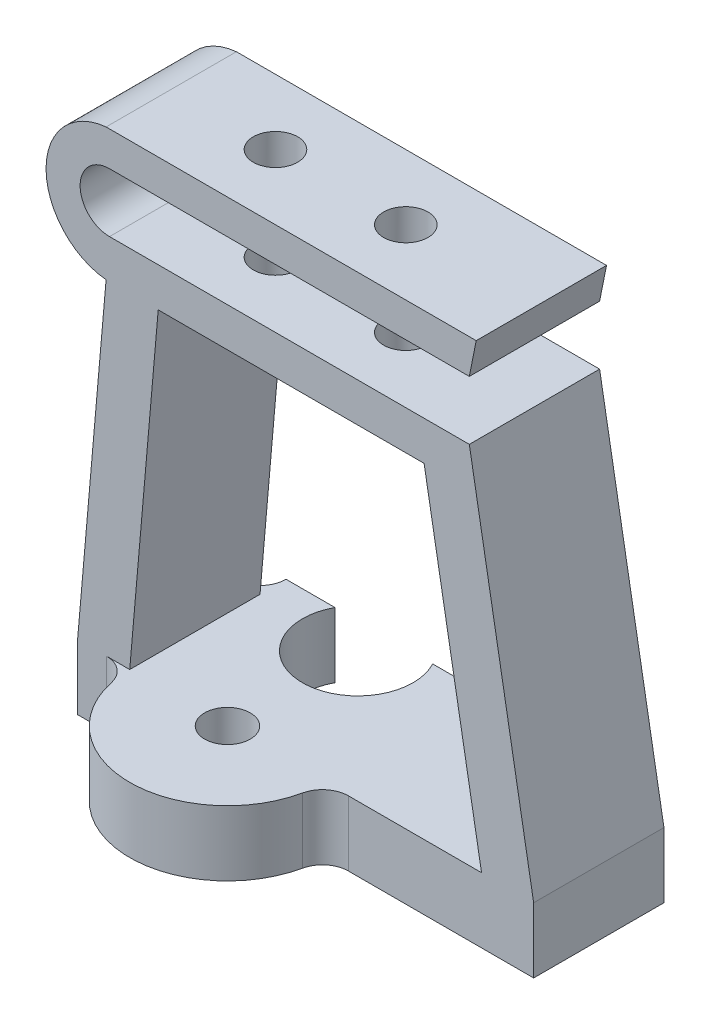
from build123d import *

# Parameters (mm, degrees)
SKETCH1_R           = 4.25
SKETCH1_R_2         = 1.75
BOSS_EXTRUDE1_DEPTH = 5
SKETCH2_W           = 10
SKETCH2_H           = 5
BOSS_EXTRUDE2_DEPTH = 16
BOSS_EXTRUDE4_START = -15
SKETCH2_2_W         = 10
SKETCH2_2_H         = 5
BOSS_EXTRUDE4_DEPTH = 4
BOSS_EXTRUDE5_DEPTH = 10
BOSS_EXTRUDE6_DEPTH = 10
FILLET7_R           = 2
SKETCH8_W           = 24.049628059
SKETCH8_H           = 16.756852772
CUT_EXTRUDE1_DEPTH  = 6
SKETCH9_R           = 1.7
CUT_EXTRUDE2_DEPTH  = 10.15756


with BuildPart() as part:
    # Sketch1 → Boss-Extrude1 (new body)
    with BuildSketch(Plane(origin=(0, 0, 0), x_dir=(1, 0, 0), z_dir=(0, 1, 0))):
        with BuildLine():
            Line((-7.5, -10), (-7.5, 10))
            ThreePointArc((-7.5, 10), (0, 17.5), (7.5, 10))
            Line((7.5, 10), (7.5, -10))
            ThreePointArc((7.5, -10), (0, -17.5), (-7.5, -10))
        make_face()
        Circle(SKETCH1_R, mode=Mode.SUBTRACT)
        with Locations((0, 10)):
            Circle(SKETCH1_R_2, mode=Mode.SUBTRACT)
        with Locations((0, -10)):
            Circle(SKETCH1_R_2, mode=Mode.SUBTRACT)
    extrude(amount=BOSS_EXTRUDE1_DEPTH)

    # Sketch2 → Boss-Extrude2 (add)
    with BuildSketch(Plane(origin=(7.5, 0, 0), x_dir=(0, 0, -1), z_dir=(1, 0, 0))):
        with Locations((-5, 2.5)):
            Rectangle(SKETCH2_W, SKETCH2_H)
    extrude(amount=BOSS_EXTRUDE2_DEPTH)

    # Sketch2_2 → Boss-Extrude4 (add)
    with BuildSketch(Plane(origin=(7.5, 0, 0), x_dir=(0, 0, -1), z_dir=(1, 0, 0)).offset(BOSS_EXTRUDE4_START)):
        with Locations((-5, 2.5)):
            Rectangle(SKETCH2_2_W, SKETCH2_2_H)
    extrude(amount=-BOSS_EXTRUDE4_DEPTH)

    # Sketch4 → Boss-Extrude5 (add)
    with BuildSketch(Plane.XY.offset(10)):
        Polygon((-9.312783412, 30), (-11.5, 5), (-7.5, 5), (-5.312783412, 30), align=None)
        Polygon((15.091825482, 30), (19.5, 5), (23.5, 5), (19.091825482, 30), align=None)
    extrude(amount=-BOSS_EXTRUDE5_DEPTH)

    # Sketch5 → Boss-Extrude6 (add)
    with BuildSketch(Plane.XY.offset(10)):
        with BuildLine():
            Line((19.091825482, 30), (-9.312783412, 30))
            ThreePointArc((-9.312783412, 30), (-13.921057054, 35.078779792), (-9.312783412, 40.157559584))
            Line((-9.312783412, 40.157559584), (19.091825482, 40.157559584))
            Line((19.091825482, 40.157559584), (18.56284454, 37.513443833))
            Line((18.56284454, 37.513443833), (-9.050317421, 37.513443833))
            ThreePointArc((-9.050317421, 37.513443833), (-11.307039338, 35.256721917), (-9.050317421, 33))
            Line((-9.050317421, 33), (18.56284454, 33))
            Line((18.56284454, 33), (19.091825482, 30))
        make_face()
    extrude(amount=-BOSS_EXTRUDE6_DEPTH)

    # Fillet7
    fillet7_edges = [part.edges().sort_by_distance(p)[0] for p in [
        (7.5, 2.5, 0),
        (-7.5, 2.5, 0),
        (-7.5, 2.5, 10),
        (7.5, 2.5, 10),
    ]]
    fillet(fillet7_edges, radius=FILLET7_R)

    # Sketch8 → Cut-Extrude1 (cut, through all)
    with BuildSketch(Plane(origin=(0, 5, 0), x_dir=(1, 0, 0), z_dir=(0, 1, 0))):
        with Locations((0.399485588, 10.378426386)):
            Rectangle(SKETCH8_W, SKETCH8_H)
    extrude(amount=-CUT_EXTRUDE1_DEPTH, mode=Mode.SUBTRACT)

    # Sketch9 → Cut-Extrude2 (cut)
    with BuildSketch(Plane(origin=(0, 40.157559584, 0), x_dir=(1, 0, 0), z_dir=(0, 1, 0))):
        with Locations((-1.312783412, -5)):
            Circle(SKETCH9_R)
        with Locations((8.687216588, -5)):
            Circle(SKETCH9_R)
    extrude(amount=-CUT_EXTRUDE2_DEPTH, mode=Mode.SUBTRACT)


solid = part.part
